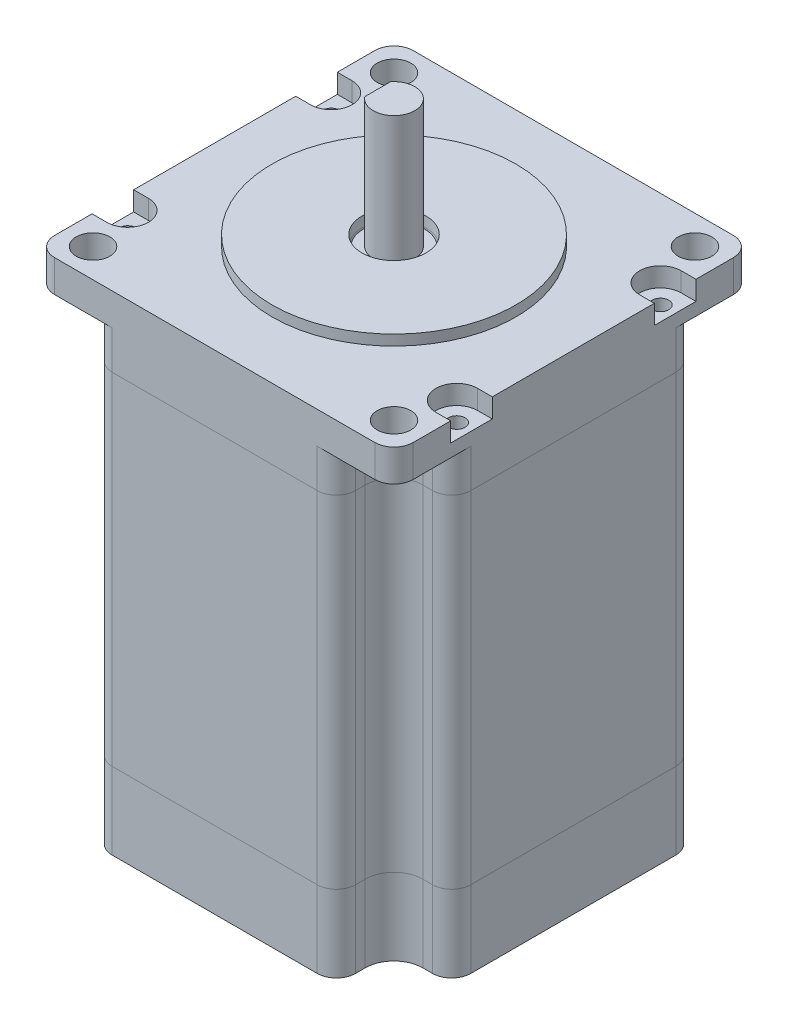
from build123d import *

# Parameters (mm, degrees)
SKETCH2_R           = 1.3
SKETCH2_R_2         = 5
BOSS_EXTRUDE2_DEPTH = 12
BOSS_EXTRUDE3_START = 12
SKETCH2_5_R         = 1.3
SKETCH2_5_R_2       = 5
BOSS_EXTRUDE3_DEPTH = 53.3
BOSS_EXTRUDE4_START = 65.3
SKETCH2_6_R         = 1.3
SKETCH2_6_R_2       = 5
BOSS_EXTRUDE4_DEPTH = 6
SKETCH4_W           = 56
SKETCH4_H           = 56
SKETCH4_R           = 2.625
SKETCH4_R_2         = 5
SKETCH4_R_3         = 1.3
BOSS_EXTRUDE5_DEPTH = 5
CUT_EXTRUDE1_START  = 2
CUT_EXTRUDE1_DEPTH  = 3
BOSS_EXTRUDE6_DEPTH = 20
SKETCH7_R           = 4.75
BOSS_EXTRUDE7_DEPTH = 74
SKETCH8_R           = 19.05
SKETCH8_R_2         = 5
BOSS_EXTRUDE8_DEPTH = 1.63
FILLET1_R           = 3


with BuildPart() as part:
    # Sketch2 → Boss-Extrude2 (new body)
    with BuildSketch(Plane(origin=(0, 0, 0), x_dir=(1, 0, 0), z_dir=(0, 1, 0))):
        with BuildLine():
            Line((-16, 28), (16, 28))
            ThreePointArc((16, 28), (18.121320344, 27.121320344), (19, 25))
            Line((19, 25), (19, 23.499265338))
            ThreePointArc((19, 23.499265338), (20.317804307, 20.317804307), (23.499265338, 19))
            Line((23.499265338, 19), (25, 19))
            ThreePointArc((25, 19), (27.121320344, 18.121320344), (28, 16))
            Line((28, 16), (28, -16))
            ThreePointArc((28, -16), (27.121320344, -18.121320344), (25, -19))
            Line((25, -19), (23.499265338, -19))
            ThreePointArc((23.499265338, -19), (20.317804307, -20.317804307), (19, -23.499265338))
            Line((19, -23.499265338), (19, -25))
            ThreePointArc((19, -25), (18.121320344, -27.121320344), (16, -28))
            Line((16, -28), (-16, -28))
            ThreePointArc((-16, -28), (-18.121320344, -27.121320344), (-19, -25))
            Line((-19, -25), (-19, -23.499265338))
            ThreePointArc((-19, -23.499265338), (-20.317804307, -20.317804307), (-23.499265338, -19))
            Line((-23.499265338, -19), (-25, -19))
            ThreePointArc((-25, -19), (-27.121320344, -18.121320344), (-28, -16))
            Line((-28, -16), (-28, 16))
            ThreePointArc((-28, 16), (-27.121320344, 18.121320344), (-25, 19))
            Line((-25, 19), (-23.499265338, 19))
            ThreePointArc((-23.499265338, 19), (-20.317804307, 20.317804307), (-19, 23.499265338))
            Line((-19, 23.499265338), (-19, 25))
            ThreePointArc((-19, 25), (-18.121320344, 27.121320344), (-16, 28))
        make_face()
        with Locations((-25.7, 15.9)):
            Circle(SKETCH2_R, mode=Mode.SUBTRACT)
        with Locations((25.7, 15.9)):
            Circle(SKETCH2_R, mode=Mode.SUBTRACT)
        with Locations((-25.7, -15.9)):
            Circle(SKETCH2_R, mode=Mode.SUBTRACT)
        with Locations((25.7, -15.9)):
            Circle(SKETCH2_R, mode=Mode.SUBTRACT)
        Circle(SKETCH2_R_2, mode=Mode.SUBTRACT)
    extrude(amount=BOSS_EXTRUDE2_DEPTH)


with BuildPart() as body_2:
    # Sketch2_5 → Boss-Extrude3 (new body)
    with BuildSketch(Plane(origin=(0, 0, 0), x_dir=(1, 0, 0), z_dir=(0, 1, 0)).offset(BOSS_EXTRUDE3_START)):
        with BuildLine():
            Line((-16, 28), (16, 28))
            ThreePointArc((16, 28), (18.121320344, 27.121320344), (19, 25))
            Line((19, 25), (19, 23.499265338))
            ThreePointArc((19, 23.499265338), (20.317804307, 20.317804307), (23.499265338, 19))
            Line((23.499265338, 19), (25, 19))
            ThreePointArc((25, 19), (27.121320344, 18.121320344), (28, 16))
            Line((28, 16), (28, -16))
            ThreePointArc((28, -16), (27.121320344, -18.121320344), (25, -19))
            Line((25, -19), (23.499265338, -19))
            ThreePointArc((23.499265338, -19), (20.317804307, -20.317804307), (19, -23.499265338))
            Line((19, -23.499265338), (19, -25))
            ThreePointArc((19, -25), (18.121320344, -27.121320344), (16, -28))
            Line((16, -28), (-16, -28))
            ThreePointArc((-16, -28), (-18.121320344, -27.121320344), (-19, -25))
            Line((-19, -25), (-19, -23.499265338))
            ThreePointArc((-19, -23.499265338), (-20.317804307, -20.317804307), (-23.499265338, -19))
            Line((-23.499265338, -19), (-25, -19))
            ThreePointArc((-25, -19), (-27.121320344, -18.121320344), (-28, -16))
            Line((-28, -16), (-28, 16))
            ThreePointArc((-28, 16), (-27.121320344, 18.121320344), (-25, 19))
            Line((-25, 19), (-23.499265338, 19))
            ThreePointArc((-23.499265338, 19), (-20.317804307, 20.317804307), (-19, 23.499265338))
            Line((-19, 23.499265338), (-19, 25))
            ThreePointArc((-19, 25), (-18.121320344, 27.121320344), (-16, 28))
        make_face()
        with Locations((-25.7, 15.9)):
            Circle(SKETCH2_5_R, mode=Mode.SUBTRACT)
        with Locations((25.7, 15.9)):
            Circle(SKETCH2_5_R, mode=Mode.SUBTRACT)
        with Locations((-25.7, -15.9)):
            Circle(SKETCH2_5_R, mode=Mode.SUBTRACT)
        with Locations((25.7, -15.9)):
            Circle(SKETCH2_5_R, mode=Mode.SUBTRACT)
        Circle(SKETCH2_5_R_2, mode=Mode.SUBTRACT)
    extrude(amount=BOSS_EXTRUDE3_DEPTH)


with BuildPart() as body_3:
    # Sketch2_6 → Boss-Extrude4 (new body)
    with BuildSketch(Plane(origin=(0, 0, 0), x_dir=(1, 0, 0), z_dir=(0, 1, 0)).offset(BOSS_EXTRUDE4_START)):
        with BuildLine():
            Line((-16, 28), (16, 28))
            ThreePointArc((16, 28), (18.121320344, 27.121320344), (19, 25))
            Line((19, 25), (19, 23.499265338))
            ThreePointArc((19, 23.499265338), (20.317804307, 20.317804307), (23.499265338, 19))
            Line((23.499265338, 19), (25, 19))
            ThreePointArc((25, 19), (27.121320344, 18.121320344), (28, 16))
            Line((28, 16), (28, -16))
            ThreePointArc((28, -16), (27.121320344, -18.121320344), (25, -19))
            Line((25, -19), (23.499265338, -19))
            ThreePointArc((23.499265338, -19), (20.317804307, -20.317804307), (19, -23.499265338))
            Line((19, -23.499265338), (19, -25))
            ThreePointArc((19, -25), (18.121320344, -27.121320344), (16, -28))
            Line((16, -28), (-16, -28))
            ThreePointArc((-16, -28), (-18.121320344, -27.121320344), (-19, -25))
            Line((-19, -25), (-19, -23.499265338))
            ThreePointArc((-19, -23.499265338), (-20.317804307, -20.317804307), (-23.499265338, -19))
            Line((-23.499265338, -19), (-25, -19))
            ThreePointArc((-25, -19), (-27.121320344, -18.121320344), (-28, -16))
            Line((-28, -16), (-28, 16))
            ThreePointArc((-28, 16), (-27.121320344, 18.121320344), (-25, 19))
            Line((-25, 19), (-23.499265338, 19))
            ThreePointArc((-23.499265338, 19), (-20.317804307, 20.317804307), (-19, 23.499265338))
            Line((-19, 23.499265338), (-19, 25))
            ThreePointArc((-19, 25), (-18.121320344, 27.121320344), (-16, 28))
        make_face()
        with Locations((-25.7, 15.9)):
            Circle(SKETCH2_6_R, mode=Mode.SUBTRACT)
        with Locations((25.7, 15.9)):
            Circle(SKETCH2_6_R, mode=Mode.SUBTRACT)
        with Locations((-25.7, -15.9)):
            Circle(SKETCH2_6_R, mode=Mode.SUBTRACT)
        with Locations((25.7, -15.9)):
            Circle(SKETCH2_6_R, mode=Mode.SUBTRACT)
        Circle(SKETCH2_6_R_2, mode=Mode.SUBTRACT)
    extrude(amount=BOSS_EXTRUDE4_DEPTH)

    # Sketch4 → Boss-Extrude5 (add)
    with BuildSketch(Plane(origin=(0, 71.3, 0), x_dir=(1, 0, 0), z_dir=(0, 1, 0))):
        Rectangle(SKETCH4_W, SKETCH4_H)
        with Locations((-23.499265338, -23.499265338)):
            Circle(SKETCH4_R, mode=Mode.SUBTRACT)
        with Locations((23.499265338, -23.499265338)):
            Circle(SKETCH4_R, mode=Mode.SUBTRACT)
        with Locations((-23.499265338, 23.499265338)):
            Circle(SKETCH4_R, mode=Mode.SUBTRACT)
        Circle(SKETCH4_R_2, mode=Mode.SUBTRACT)
        with Locations((23.499265338, 23.499265338)):
            Circle(SKETCH4_R, mode=Mode.SUBTRACT)
        with Locations((-25.7, 15.9)):
            Circle(SKETCH4_R_3, mode=Mode.SUBTRACT)
        with Locations((25.7, 15.9)):
            Circle(SKETCH4_R_3, mode=Mode.SUBTRACT)
        with Locations((-25.7, -15.9)):
            Circle(SKETCH4_R_3, mode=Mode.SUBTRACT)
        with Locations((25.7, -15.9)):
            Circle(SKETCH4_R_3, mode=Mode.SUBTRACT)
    extrude(amount=BOSS_EXTRUDE5_DEPTH)

    # Sketch5 → Cut-Extrude1 (cut)
    with BuildSketch(Plane(origin=(0, 71.3, 0), x_dir=(1, 0, 0), z_dir=(0, 1, 0)).offset(CUT_EXTRUDE1_START)):
        with BuildLine():
            Line((-28, 19.15), (-28, 12.65))
            Line((-28, 12.65), (-25.7, 12.65))
            ThreePointArc((-25.7, 12.65), (-22.45, 15.9), (-25.7, 19.15))
            Line((-25.7, 19.15), (-28, 19.15))
        make_face()
        with BuildLine():
            Line((25.7, 19.15), (28, 19.15))
            Line((28, 19.15), (28, 12.65))
            Line((28, 12.65), (25.7, 12.65))
            ThreePointArc((25.7, 12.65), (22.45, 15.9), (25.7, 19.15))
        make_face()
        with BuildLine():
            Line((28, -19.15), (28, -12.65))
            Line((28, -12.65), (25.7, -12.65))
            ThreePointArc((25.7, -12.65), (22.45, -15.9), (25.7, -19.15))
            Line((25.7, -19.15), (28, -19.15))
        make_face()
        with BuildLine():
            Line((-25.7, -19.15), (-28, -19.15))
            Line((-28, -19.15), (-28, -12.65))
            Line((-28, -12.65), (-25.7, -12.65))
            ThreePointArc((-25.7, -12.65), (-22.45, -15.9), (-25.7, -19.15))
        make_face()
    extrude(amount=CUT_EXTRUDE1_DEPTH, mode=Mode.SUBTRACT)

    # Fillet1
    fillet1_edges = [body_3.edges().sort_by_distance(p)[0] for p in [
        (-28, 73.8, -28),
        (-28, 73.8, 28),
        (28, 73.8, 28),
        (28, 73.8, -28),
    ]]
    fillet(fillet1_edges, radius=FILLET1_R)


with BuildPart() as body_4:
    # Sketch6 → Boss-Extrude6 (new body)
    with BuildSketch(Plane(origin=(0, 76.3, 0), x_dir=(1, 0, 0), z_dir=(0, 1, 0))):
        with BuildLine():
            Line((-2.55, -2.014944168), (-2.55, 2.014944168))
            ThreePointArc((-2.55, 2.014944168), (3.25, 0), (-2.55, -2.014944168))
        make_face()
    extrude(amount=BOSS_EXTRUDE6_DEPTH)


with BuildPart() as body_5:
    # Sketch7 → Boss-Extrude7 (new body)
    with BuildSketch(Plane(origin=(0, 76.3, 0), x_dir=(1, 0, 0), z_dir=(0, 1, 0))):
        Circle(SKETCH7_R)
    extrude(amount=-BOSS_EXTRUDE7_DEPTH)


with BuildPart() as body_6:
    # Sketch8 → Boss-Extrude8 (new body)
    with BuildSketch(Plane(origin=(0, 76.3, 0), x_dir=(1, 0, 0), z_dir=(0, 1, 0))):
        Circle(SKETCH8_R)
        Circle(SKETCH8_R_2, mode=Mode.SUBTRACT)
    extrude(amount=BOSS_EXTRUDE8_DEPTH)


solid = Compound([part.part, body_2.part, body_3.part, body_4.part, body_5.part, body_6.part])
